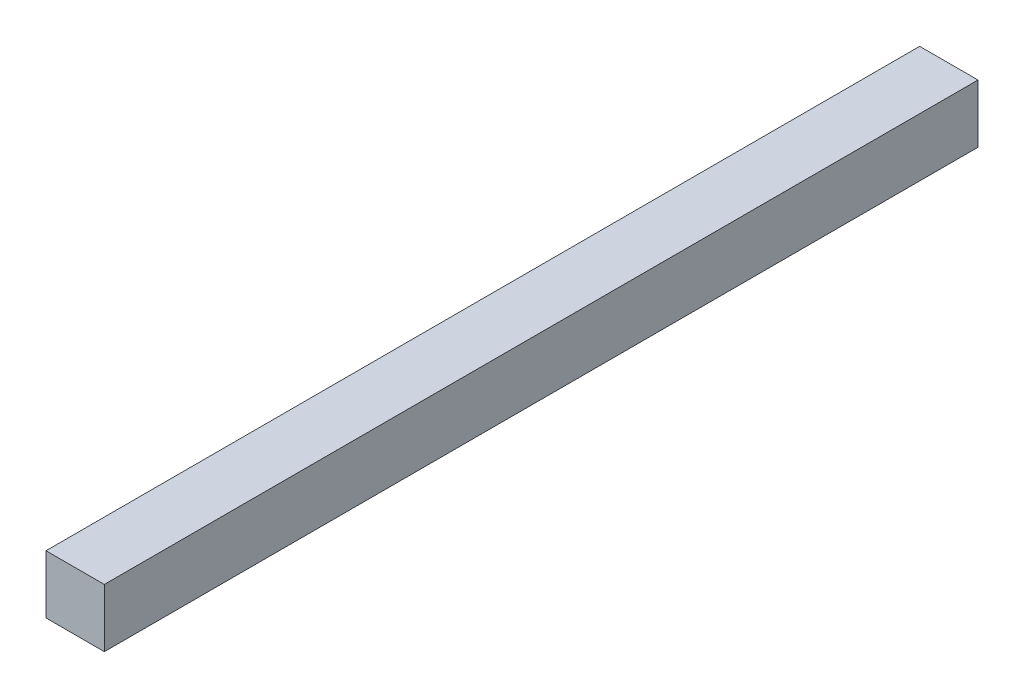
from build123d import *

# Parameters (mm, degrees)
ESBO_O2_W                = 30.045415171
ESBO_O2_H                = 30
RESSALTO_EXTRUS_O1_DEPTH = 225


with BuildPart() as part:
    # Esboço2 → Ressalto-extrusão1 (new body, symmetric)
    with BuildSketch(Plane.XY):
        with Locations((-95.635568537, 15)):
            Rectangle(ESBO_O2_W, ESBO_O2_H)
    extrude(amount=RESSALTO_EXTRUS_O1_DEPTH, both=True)


solid = part.part
